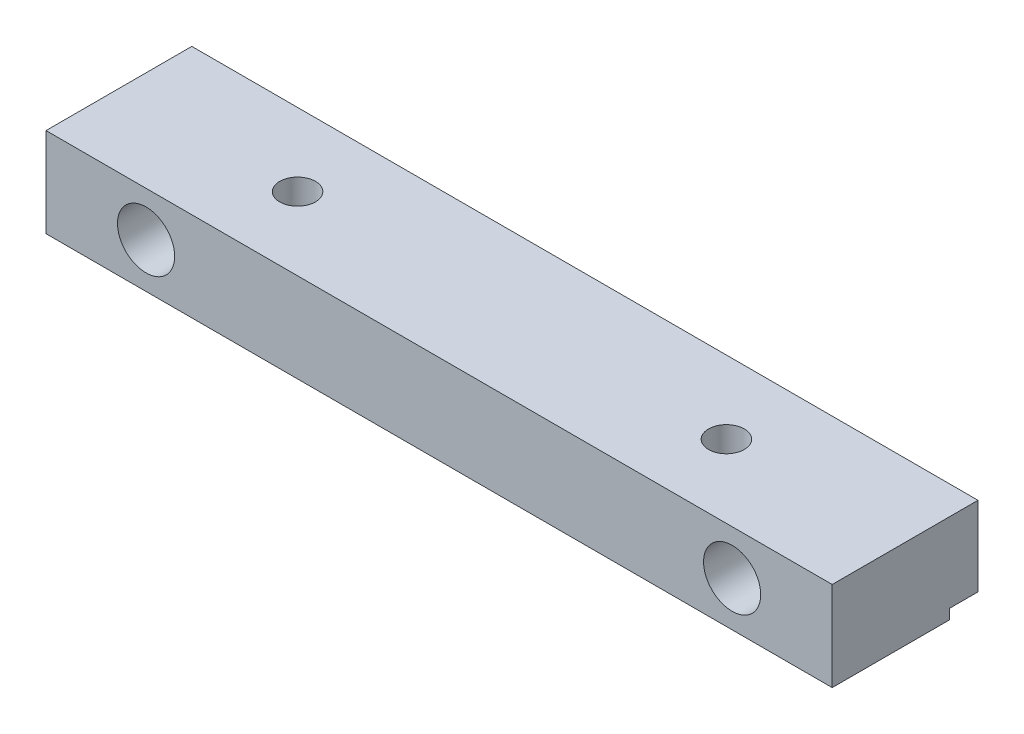
from build123d import *

# Parameters (mm, degrees)
SKETCH1_W                  = 55
SKETCH1_H                  = 10.2
BOSS_EXTRUDE1_DEPTH        = 6.25
F_4_0_4_DIAMETER_HOLE1_D   = 4
F_2_5_2_5_DIAMETER_HOLE1_D = 2.5
SKETCH6_W                  = 2
SKETCH6_H                  = 0.7
CUT_EXTRUDE1_DEPTH         = 56


with BuildPart() as part:
    # Sketch1 → Boss-Extrude1 (new body)
    with BuildSketch(Plane(origin=(0, 0, 0), x_dir=(1, 0, 0), z_dir=(0, 1, 0))):
        with Locations((27.5, 5.1)):
            Rectangle(SKETCH1_W, SKETCH1_H)
    extrude(amount=BOSS_EXTRUDE1_DEPTH)

    # Ø4.0 (4) Diameter Hole1 (through all)
    with Locations(Plane.XY):
        with Locations((7, 3.125), (48, 3.125)):
            Hole(F_4_0_4_DIAMETER_HOLE1_D / 2)

    # Ø2.5 (2.5) Diameter Hole1 (through all)
    with Locations(Plane(origin=(0, 6.25, 0), x_dir=(-1, 0, 0), z_dir=(0, 1, 0))):
        with Locations((-12.5, -5.1), (-42.5, -5.1)):
            Hole(F_2_5_2_5_DIAMETER_HOLE1_D / 2)

    # Sketch6 → Cut-Extrude1 (cut, through all)
    with BuildSketch(Plane(origin=(55, 0, 0), x_dir=(0, 0, -1), z_dir=(1, 0, 0))):
        with Locations((9.2, 0.35)):
            Rectangle(SKETCH6_W, SKETCH6_H)
    extrude(amount=-CUT_EXTRUDE1_DEPTH, mode=Mode.SUBTRACT)


solid = part.part
